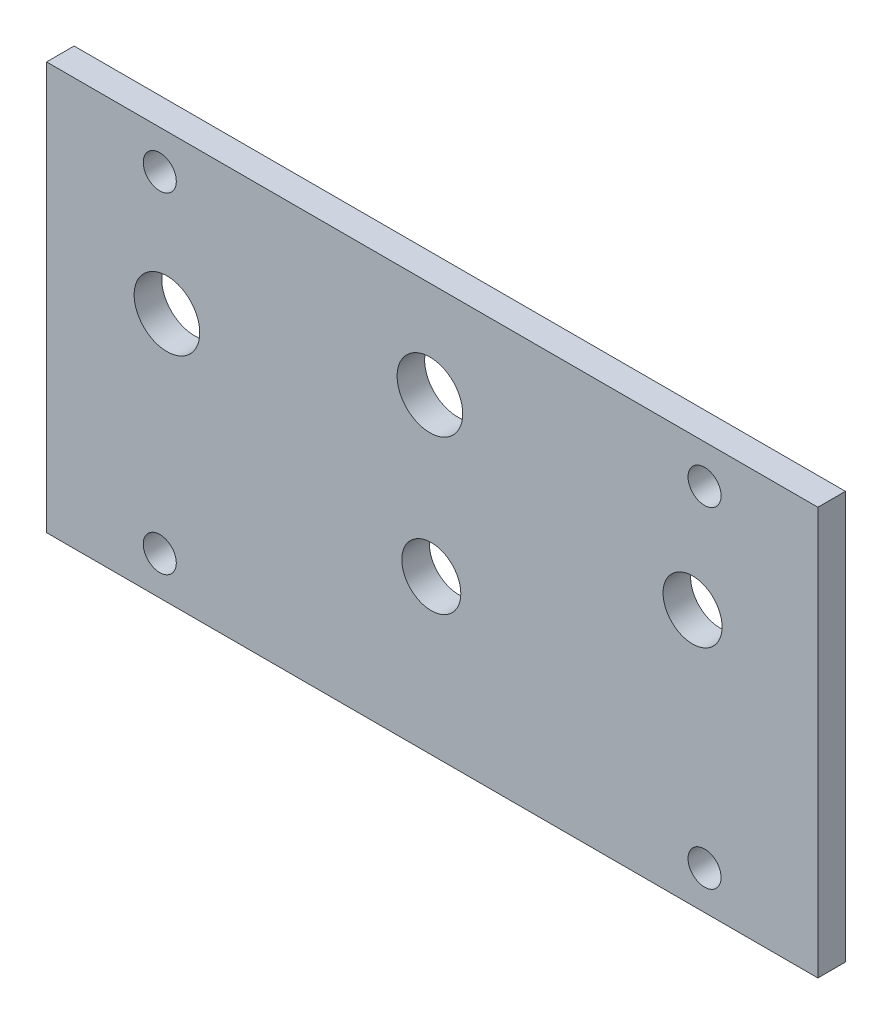
from build123d import *

# Parameters (mm, degrees)
SKETCH1_W           = 88.9
SKETCH1_H           = 46.99
SKETCH1_R           = 1.905
BOSS_EXTRUDE1_DEPTH = 3.175


with BuildPart() as part:
    # Sketch1 → Boss-Extrude1 (new body)
    with BuildSketch(Plane.XY):
        with Locations((80.175941247, 30.1625)):
            Rectangle(SKETCH1_W, SKETCH1_H)
        with Locations((48.77435, 49.2125)):
            Circle(SKETCH1_R, mode=Mode.SUBTRACT)
        with Locations((111.56315, 49.2125)):
            Circle(SKETCH1_R, mode=Mode.SUBTRACT)
        with Locations((48.77435, 11.1125)):
            Circle(SKETCH1_R, mode=Mode.SUBTRACT)
        with Locations((111.56315, 11.1125)):
            Circle(SKETCH1_R, mode=Mode.SUBTRACT)
        with BuildLine():
            ThreePointArc((83.469406447, 24.4520759), (80.069406447, 27.8520759), (76.669406447, 24.4520759))
            ThreePointArc((76.669406447, 24.4520759), (80.069406447, 21.0520759), (83.469406447, 24.4520759))
        make_face(mode=Mode.SUBTRACT)
        with BuildLine():
            ThreePointArc((106.780920888, 36.184870981), (110.180920888, 32.784870981), (113.580920888, 36.184870981))
            ThreePointArc((113.580920888, 36.184870981), (110.180920888, 39.584870981), (106.780920888, 36.184870981))
        make_face(mode=Mode.SUBTRACT)
        with BuildLine():
            ThreePointArc((53.381968416, 35.458841184), (49.600968416, 39.239841184), (45.819968416, 35.458841184))
            ThreePointArc((45.819968416, 35.458841184), (49.600968416, 31.677841184), (53.381968416, 35.458841184))
        make_face(mode=Mode.SUBTRACT)
        with BuildLine():
            ThreePointArc((83.689808954, 42.509614322), (79.908808954, 46.290614322), (76.127808954, 42.509614322))
            ThreePointArc((76.127808954, 42.509614322), (79.908808954, 38.728614322), (83.689808954, 42.509614322))
        make_face(mode=Mode.SUBTRACT)
    extrude(amount=BOSS_EXTRUDE1_DEPTH)


solid = part.part
